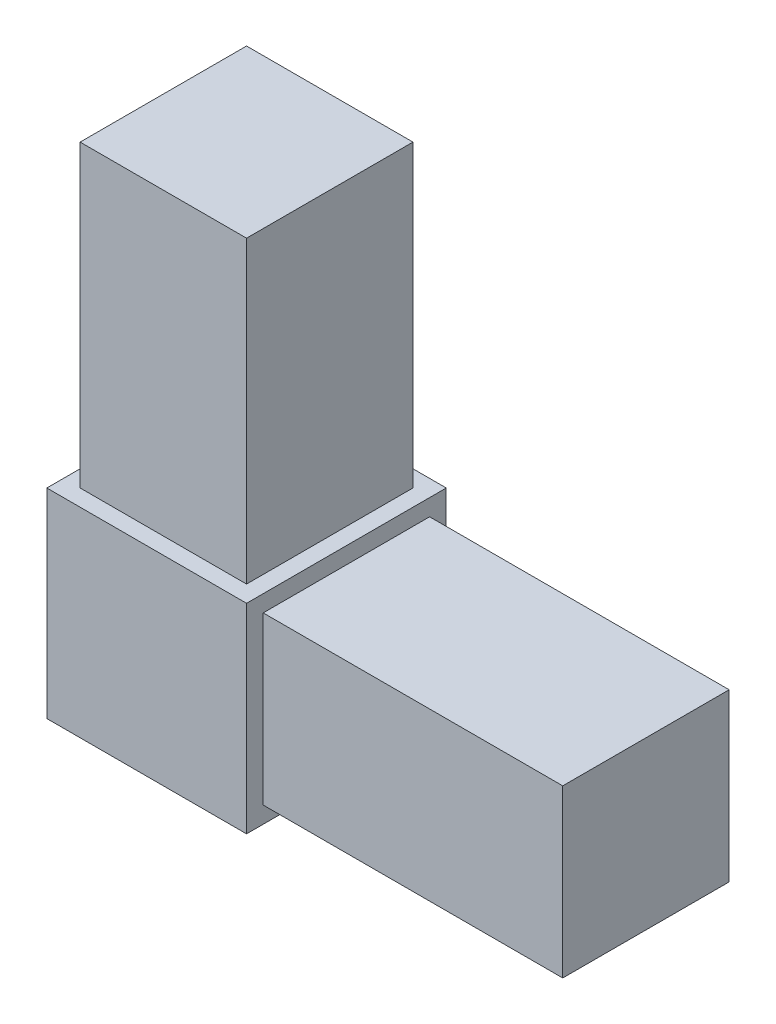
from build123d import *

# Parameters (mm, degrees)
SKETCH1_W           = 19.05
SKETCH1_H           = 19.05
BOSS_EXTRUDE1_DEPTH = 19.05
SKETCH2_W           = 15.875
SKETCH2_H           = 15.875
BOSS_EXTRUDE2_DEPTH = 28.575
SKETCH3_W           = 15.875
SKETCH3_H           = 15.875
BOSS_EXTRUDE3_DEPTH = 28.575


with BuildPart() as part:
    # Sketch1 → Boss-Extrude1 (new body)
    with BuildSketch(Plane.XY):
        Rectangle(SKETCH1_W, SKETCH1_H)
    extrude(amount=BOSS_EXTRUDE1_DEPTH)

    # Sketch2 → Boss-Extrude2 (add)
    with BuildSketch(Plane(origin=(0, 9.525, 0), x_dir=(1, 0, 0), z_dir=(0, 1, 0))):
        with Locations((0, -9.525)):
            Rectangle(SKETCH2_W, SKETCH2_H)
    extrude(amount=BOSS_EXTRUDE2_DEPTH)

    # Sketch3 → Boss-Extrude3 (add)
    with BuildSketch(Plane(origin=(9.525, 0, 0), x_dir=(0, 0, -1), z_dir=(1, 0, 0))):
        with Locations((-9.525, 0)):
            Rectangle(SKETCH3_W, SKETCH3_H)
    extrude(amount=BOSS_EXTRUDE3_DEPTH)


solid = part.part
